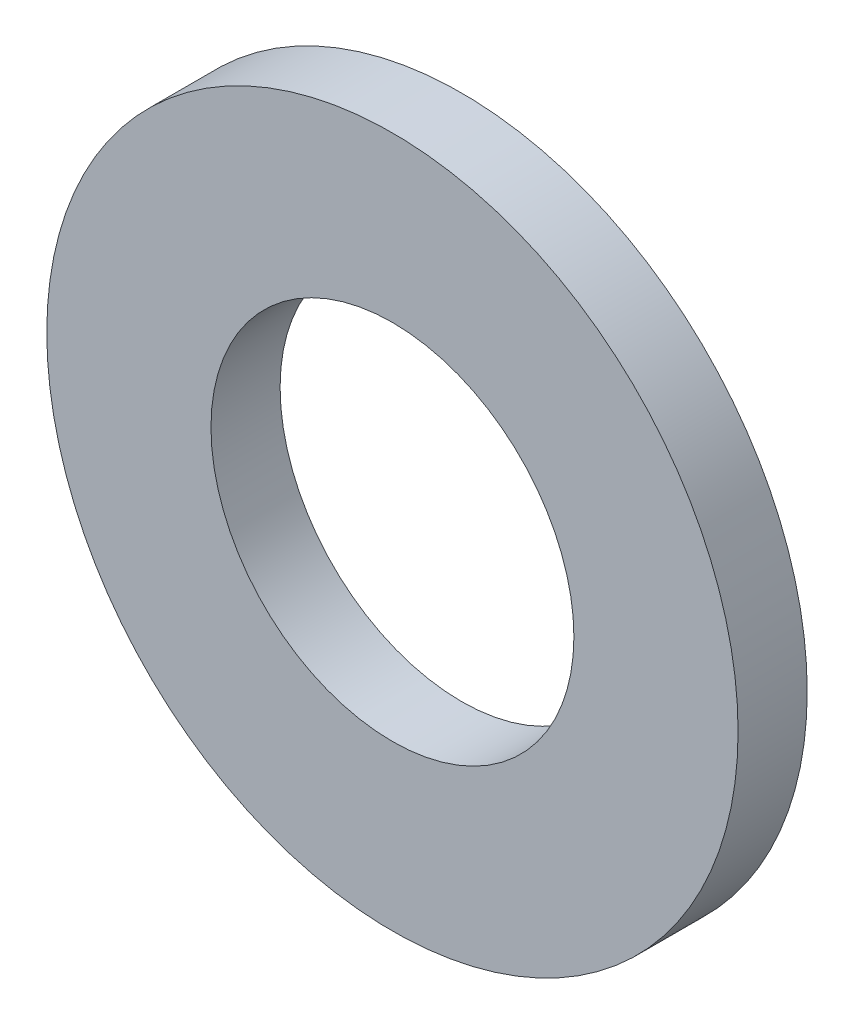
from build123d import *

# Parameters (mm, degrees)
SKETCH_1_R      = 8
SKETCH_1_R_2    = 4.2
EXTRUDE_1_DEPTH = 1.6


with BuildPart() as part:
    # Эскиз1 → Бобышка-Вытянуть1 (new body)
    with BuildSketch(Plane.XY):
        Circle(SKETCH_1_R)
        Circle(SKETCH_1_R_2, mode=Mode.SUBTRACT)
    extrude(amount=EXTRUDE_1_DEPTH)


solid = part.part
